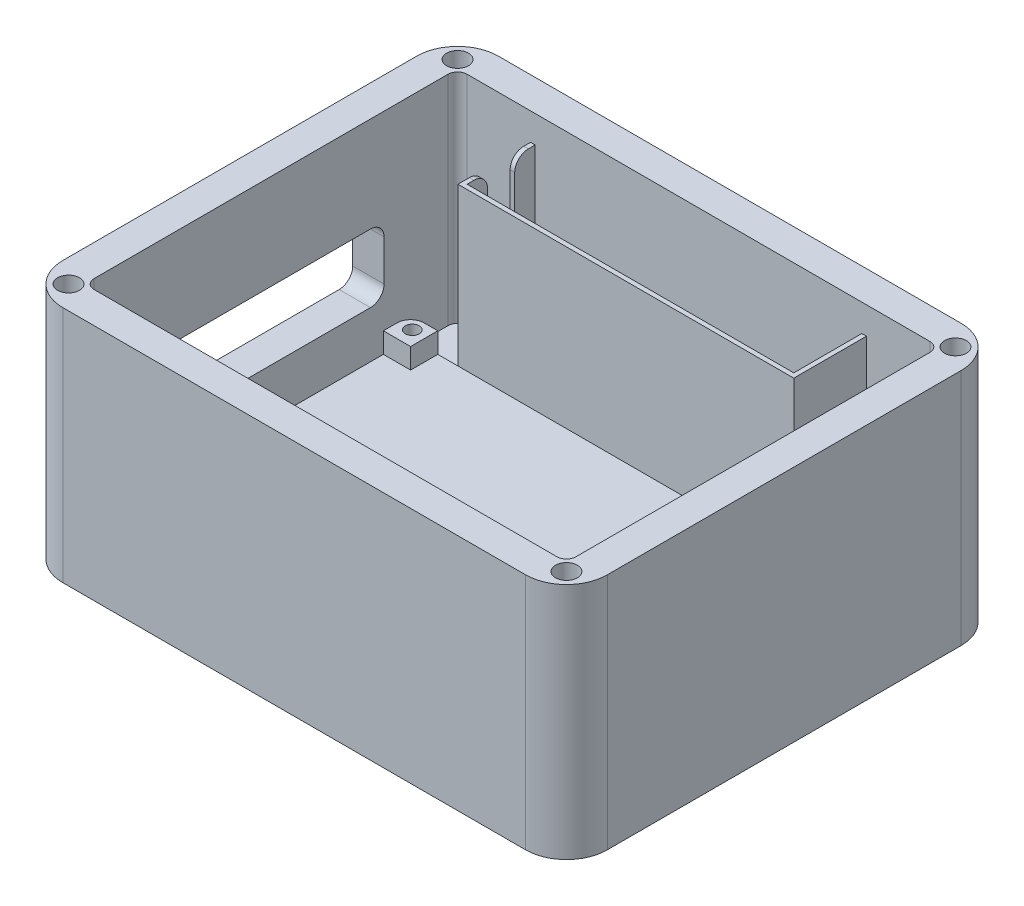
from build123d import *

# Parameters (mm, degrees)
BASE_PLATE_DEPTH                        = 4.7625
OUTSIDEBOSS_DEPTH                       = 50.8
TOPPLATE_MOUNTINGHOLE_8_0_199_DIAMETE_D = 5.1054
PCB_PLATE_DEPTH                         = 12.7
F_4_CLEARANCE_HOLE1_D                   = 3.2639
F_4_CLEARANCE_HOLE1_DEPTH               = 16.002
F_4_CLEARANCE_HOLE1_TIP                 = 0.980574487
SKETCH11_W                              = 87.3125
SKETCH11_H                              = 50.8
SKETCH11_W_2                            = 6.35
SKETCH11_H_2                            = 6.35
CUT_EXTRUDE2_DEPTH                      = 4.7625
SKETCH12_W                              = 78.3336
SKETCH12_H                              = 18.0086
SKETCH12_W_2                            = 76.2
SKETCH12_H_2                            = 15.875
BATTERYHOLDER_DEPTH                     = 44.45
BATTERYLEADFEADER_REACH                 = 128.453
BATTERYLEADFILLETS_R                    = 3.175
CUT_EXTRUDE3_REACH                      = 149.637


with BuildPart() as part:
    # Sketch1 → Base_Plate (new body)
    with BuildSketch(Plane(origin=(0, 0, 0), x_dir=(1, 0, 0), z_dir=(0, 1, 0))):
        with BuildLine():
            Line((-53.975, 50.8), (53.975, 50.8))
            ThreePointArc((53.975, 50.8), (60.710192091, 48.010192091), (63.5, 41.275))
            Line((63.5, 41.275), (63.5, -41.275))
            ThreePointArc((63.5, -41.275), (60.710192091, -48.010192091), (53.975, -50.8))
            Line((53.975, -50.8), (-53.975, -50.8))
            ThreePointArc((-53.975, -50.8), (-60.710192091, -48.010192091), (-63.5, -41.275))
            Line((-63.5, -41.275), (-63.5, 41.275))
            ThreePointArc((-63.5, 41.275), (-60.710192091, 48.010192091), (-53.975, 50.8))
        make_face()
    extrude(amount=BASE_PLATE_DEPTH)

    # Sketch2 → OutsideBoss (add)
    with BuildSketch(Plane(origin=(0, 4.7625, 0), x_dir=(1, 0, 0), z_dir=(0, 1, 0))):
        with BuildLine():
            Line((-53.975, -50.8), (53.975, -50.8))
            ThreePointArc((53.975, -50.8), (60.710192091, -48.010192091), (63.5, -41.275))
            Line((63.5, -41.275), (63.5, 41.275))
            ThreePointArc((63.5, 41.275), (60.710192091, 48.010192091), (53.975, 50.8))
            Line((53.975, 50.8), (-53.975, 50.8))
            ThreePointArc((-53.975, 50.8), (-60.710192091, 48.010192091), (-63.5, 41.275))
            Line((-63.5, 41.275), (-63.5, -41.275))
            ThreePointArc((-63.5, -41.275), (-60.710192091, -48.010192091), (-53.975, -50.8))
        make_face()
        with BuildLine():
            Line((-56.1975, 41.275), (-56.1975, -41.275))
            ThreePointArc((-56.1975, -41.275), (-55.546544821, -42.846544821), (-53.975, -43.4975))
            Line((-53.975, -43.4975), (53.975, -43.4975))
            ThreePointArc((53.975, -43.4975), (55.546544821, -42.846544821), (56.1975, -41.275))
            Line((56.1975, -41.275), (56.1975, 41.275))
            ThreePointArc((56.1975, 41.275), (55.546544821, 42.846544821), (53.975, 43.4975))
            Line((53.975, 43.4975), (-53.975, 43.4975))
            ThreePointArc((-53.975, 43.4975), (-55.546544821, 42.846544821), (-56.1975, 41.275))
        make_face(mode=Mode.SUBTRACT)
    extrude(amount=OUTSIDEBOSS_DEPTH)

    # TopPlate_MountingHole_#8 (0.199) Diameter Hole1 (through all)
    with Locations(Plane(origin=(0, 0, 0), x_dir=(-1, 0, 0), z_dir=(0, -1, 0))):
        with Locations((-58.07075, 45.37075), (58.07075, -45.37075), (-58.07075, -45.37075), (58.07075, 45.37075)):
            Hole(TOPPLATE_MOUNTINGHOLE_8_0_199_DIAMETE_D / 2)

    # Sketch8 → PCB_Plate (add)
    with BuildSketch(Plane(origin=(0, 4.7625, 0), x_dir=(1, 0, 0), z_dir=(0, 1, 0))):
        with BuildLine():
            Line((46.83125, -37.1475), (-46.83125, -37.1475))
            ThreePointArc((-46.83125, -37.1475), (-49.07631403, -36.21756403), (-50.00625, -33.9725))
            Line((-50.00625, -33.9725), (-50.00625, 23.1775))
            ThreePointArc((-50.00625, 23.1775), (-49.07631403, 25.42256403), (-46.83125, 26.3525))
            Line((-46.83125, 26.3525), (46.83125, 26.3525))
            ThreePointArc((46.83125, 26.3525), (49.07631403, 25.42256403), (50.00625, 23.1775))
            Line((50.00625, 23.1775), (50.00625, -33.9725))
            ThreePointArc((50.00625, -33.9725), (49.07631403, -36.21756403), (46.83125, -37.1475))
        make_face()
    extrude(amount=PCB_PLATE_DEPTH)

    # #4 Clearance Hole1
    with Locations(Plane(origin=(0, 17.4625, 0), x_dir=(1, 0, 0), z_dir=(0, 1, 0))):
        with Locations((-46.83125, 23.574375), (46.83125, 23.574375), (-46.83125, -34.369375), (46.83125, -34.369375)):
            Hole(F_4_CLEARANCE_HOLE1_D / 2, depth=F_4_CLEARANCE_HOLE1_DEPTH)
            with Locations((0, 0, -(F_4_CLEARANCE_HOLE1_DEPTH + F_4_CLEARANCE_HOLE1_TIP / 2))):  # 118° drill point
                Cone(0, F_4_CLEARANCE_HOLE1_D / 2, F_4_CLEARANCE_HOLE1_TIP, mode=Mode.SUBTRACT)

    # Sketch11 → Cut-Extrude2 (cut)
    with BuildSketch(Plane(origin=(0, 17.4625, 0), x_dir=(1, 0, 0), z_dir=(0, 1, 0))):
        with Locations((0, -5.3975)):
            Rectangle(SKETCH11_W, SKETCH11_H)
        with Locations((46.83125, -5.3975)):
            Rectangle(SKETCH11_W_2, SKETCH11_H)
        with Locations((0, 23.1775)):
            Rectangle(SKETCH11_W, SKETCH11_H_2)
        with Locations((0, -33.9725)):
            Rectangle(SKETCH11_W, SKETCH11_H_2)
        with Locations((-46.83125, -5.3975)):
            Rectangle(SKETCH11_W_2, SKETCH11_H)
    extrude(amount=-CUT_EXTRUDE2_DEPTH, mode=Mode.SUBTRACT)

    # Sketch12 → BatteryHolder (add)
    with BuildSketch(Plane(origin=(0, 4.7625, 0), x_dir=(1, 0, 0), z_dir=(0, 1, 0))):
        with Locations((0, 35.56)):
            Rectangle(SKETCH12_W, SKETCH12_H)
        with Locations((0, 35.56)):
            Rectangle(SKETCH12_W_2, SKETCH12_H_2, mode=Mode.SUBTRACT)
    extrude(amount=BATTERYHOLDER_DEPTH)

    # Sketch13 → BatteryLeadFeader (cut, up to next)
    with BuildSketch(Plane(origin=(-38.1, 0, 0), x_dir=(0, 0, -1), z_dir=(1, 0, 0)), mode=Mode.PRIVATE) as batteryleadfeader_sk1:
        with BuildLine():
            Line((38.735, 23.8125), (38.735, 49.2125))
            Line((38.735, 49.2125), (32.385, 49.2125))
            Line((32.385, 49.2125), (32.385, 23.8125))
            ThreePointArc((32.385, 23.8125), (35.56, 26.9875), (38.735, 23.8125))
        make_face()
    batteryleadfeader_tool1 = extrude(batteryleadfeader_sk1.sketch, amount=-BATTERYLEADFEADER_REACH, mode=Mode.PRIVATE) & part.part
    # Sketch13 → BatteryLeadFeader (cut, up to next)
    with BuildSketch(Plane(origin=(-38.1, 0, 0), x_dir=(0, 0, -1), z_dir=(1, 0, 0)), mode=Mode.PRIVATE) as batteryleadfeader_sk2:
        with BuildLine():
            ThreePointArc((32.385, 23.8125), (35.56, 20.6375), (38.735, 23.8125))
            Line((38.735, 23.8125), (32.385, 23.8125))
        make_face()
    batteryleadfeader_tool2 = extrude(batteryleadfeader_sk2.sketch, amount=-BATTERYLEADFEADER_REACH, mode=Mode.PRIVATE) & part.part
    # Sketch13 → BatteryLeadFeader (cut, up to next)
    with BuildSketch(Plane(origin=(-38.1, 0, 0), x_dir=(0, 0, -1), z_dir=(1, 0, 0)), mode=Mode.PRIVATE) as batteryleadfeader_sk3:
        with BuildLine():
            Line((32.385, 23.8125), (38.735, 23.8125))
            ThreePointArc((38.735, 23.8125), (35.56, 26.9875), (32.385, 23.8125))
        make_face()
    batteryleadfeader_tool3 = extrude(batteryleadfeader_sk3.sketch, amount=-BATTERYLEADFEADER_REACH, mode=Mode.PRIVATE) & part.part
    # Sketch13 → BatteryLeadFeader (cut, up to next)
    with BuildSketch(Plane(origin=(-38.1, 0, 0), x_dir=(0, 0, -1), z_dir=(1, 0, 0)), mode=Mode.PRIVATE) as batteryleadfeader_sk4:
        with BuildLine():
            ThreePointArc((32.385, 23.8125), (35.56, 20.6375), (38.735, 23.8125))
            Line((38.735, 23.8125), (32.385, 23.8125))
        make_face()
    batteryleadfeader_tool4 = extrude(batteryleadfeader_sk4.sketch, amount=-BATTERYLEADFEADER_REACH, mode=Mode.PRIVATE) & part.part
    # Sketch13 → BatteryLeadFeader (cut, up to next)
    with BuildSketch(Plane(origin=(-38.1, 0, 0), x_dir=(0, 0, -1), z_dir=(1, 0, 0)), mode=Mode.PRIVATE) as batteryleadfeader_sk5:
        with BuildLine():
            Line((32.385, 23.8125), (38.735, 23.8125))
            ThreePointArc((38.735, 23.8125), (35.56, 26.9875), (32.385, 23.8125))
        make_face()
    batteryleadfeader_tool5 = extrude(batteryleadfeader_sk5.sketch, amount=-BATTERYLEADFEADER_REACH, mode=Mode.PRIVATE) & part.part
    add(batteryleadfeader_tool1.solids().sort_by_distance((-38.1, 37.748358, -35.56))[0], mode=Mode.SUBTRACT)
    add(batteryleadfeader_tool2.solids().sort_by_distance((-38.1, 22.464988, -35.56))[0], mode=Mode.SUBTRACT)
    add(batteryleadfeader_tool3.solids().sort_by_distance((-38.1, 25.160012, -35.56))[0], mode=Mode.SUBTRACT)
    add(batteryleadfeader_tool4.solids().sort_by_distance((-38.1, 22.464988, -35.56))[0], mode=Mode.SUBTRACT)
    add(batteryleadfeader_tool5.solids().sort_by_distance((-38.1, 25.160012, -35.56))[0], mode=Mode.SUBTRACT)

    # BatteryLeadFillets
    batteryleadfillets_edges = [part.edges().sort_by_distance(p)[0] for p in [
        (-38.6334, 49.2125, -38.735),
        (-38.6334, 49.2125, -32.385),
    ]]
    fillet(batteryleadfillets_edges, radius=BATTERYLEADFILLETS_R)

    # Sketch14 → Cut-Extrude3 (cut, up to next)
    with BuildSketch(Plane.ZY.offset(63.5), mode=Mode.PRIVATE) as cut_extrude3_sk1:
        with BuildLine():
            Line((-26.3525, 20.6375), (-26.3525, 30.1625))
            ThreePointArc((-26.3525, 30.1625), (-25.42256403, 32.40756403), (-23.1775, 33.3375))
            Line((-23.1775, 33.3375), (33.9725, 33.3375))
            ThreePointArc((33.9725, 33.3375), (36.21756403, 32.40756403), (37.1475, 30.1625))
            Line((37.1475, 30.1625), (37.1475, 20.6375))
            ThreePointArc((37.1475, 20.6375), (36.21756403, 18.39243597), (33.9725, 17.4625))
            Line((33.9725, 17.4625), (-23.1775, 17.4625))
            ThreePointArc((-23.1775, 17.4625), (-25.42256403, 18.39243597), (-26.3525, 20.6375))
        make_face()
    cut_extrude3_tool1 = extrude(cut_extrude3_sk1.sketch, amount=-CUT_EXTRUDE3_REACH, mode=Mode.PRIVATE) & part.part
    add(cut_extrude3_tool1.solids().sort_by_distance((-63.5, 25.4, 5.3975))[0], mode=Mode.SUBTRACT)


solid = part.part
